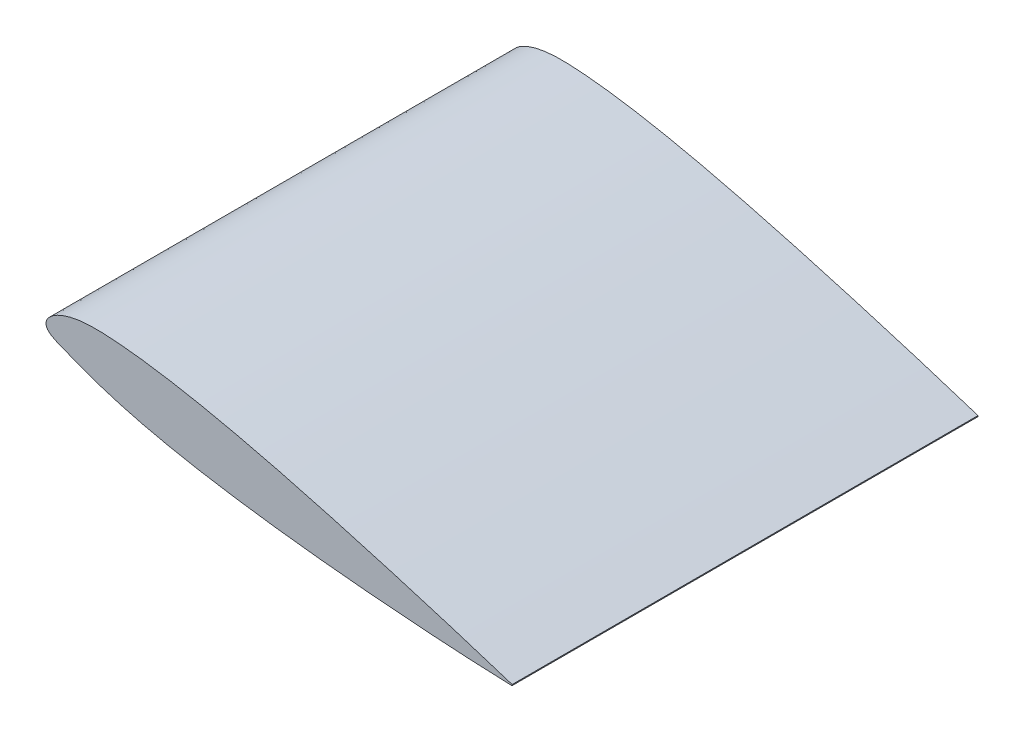
from build123d import *

# Parameters (mm, degrees)
DODANIE_WYCI_GNI_CIE1_DEPTH = 500


with BuildPart() as part:
    # Szkic1 → Dodanie-wyciągnięcie1 (new body)
    with BuildSketch(Plane.XY):
        with BuildLine():
            Line((500.236459207, -86.822463551), (500.014537954, -88.081041521))
            add(Edge.make_bspline(
                [(500.236459207, -86.822463551), (476.50302096, -79.117627864), (435.907347365, -66.352488826), (379.635127422, -49.432082907), (330.514532249, -35.210280772), (285.390965798, -22.736898114), (243.035728266, -11.710531457), (204.980392695, -2.498199851), (171.80378187, 4.744920732), (143.853586045, 10.126598704), (121.256292773, 13.934358096), (103.222511953, 16.4662337), (89.542486088, 18.038612433), (79.917866709, 18.972057051), (70.671398127, 19.678496533), (61.73121741, 20.188531005), (53.050632583, 20.386993119), (44.698296901, 20.171104888), (36.800756888, 19.484592527), (29.478604607, 18.316932041), (22.839289587, 16.700348263), (16.970164303, 14.700825556), (11.933719982, 12.406207295), (7.766023129, 9.912894215), (4.478256402, 7.312706017), (2.061779891, 4.680346152), (0.49841815, 2.063407037), (-0.212639902, -0.51684831), (-0.054787304, -2.992092218), (0.889889683, -5.26455614), (2.523894842, -7.288235737), (4.74064393, -9.105105292), (7.481894176, -10.788420727), (10.703896378, -12.401764648), (14.37055538, -14.00303941), (18.457361048, -15.645087446), (22.957356031, -17.375361521), (27.885635611, -19.235139498), (35.445075277, -22.070458454), (43.760969361, -25.174860079), (52.968044403, -28.495360735), (60.956206093, -31.233352864), (76.226469953, -36.053410227), (96.125750191, -41.472432941), (124.888774814, -48.175625048), (156.417792573, -54.449808774), (193.790729033, -60.710631254), (232.612641243, -66.245506853), (276.130874858, -71.585215369), (322.782776336, -76.438328082), (373.818568697, -80.884488537), (426.854937764, -84.659773211), (468.930220781, -86.892132863), (493.883055309, -87.863742522), (499.547240989, -88.064589736), (500.014537954, -88.081041521)],
                knots=[0, 0, 0, 0, 0.072255025, 0.123222089, 0.170150758, 0.220331601, 0.258781731, 0.296881738, 0.33370442, 0.357104545, 0.379297669, 0.400055439, 0.409830087, 0.419169499, 0.428054093, 0.436681353, 0.445096795, 0.453189549, 0.460862875, 0.468034876, 0.474639206, 0.480625941, 0.485962658, 0.490636119, 0.494655605, 0.498059761, 0.500929183, 0.503404007, 0.505690993, 0.507976562, 0.510416375, 0.513147824, 0.516239073, 0.519713615, 0.52357445, 0.527821966, 0.532466294, 0.537534822, 0.543074939, 0.555844991, 0.563237839, 0.571415939, 0.580295189, 0.609601939, 0.631115834, 0.665807087, 0.702674524, 0.740833419, 0.779352204, 0.829629038, 0.87664464, 0.92769048, 0.983588069, 0.998646023, 1, 1, 1, 1], degree=3))
        make_face()
    extrude(amount=DODANIE_WYCI_GNI_CIE1_DEPTH)


solid = part.part
